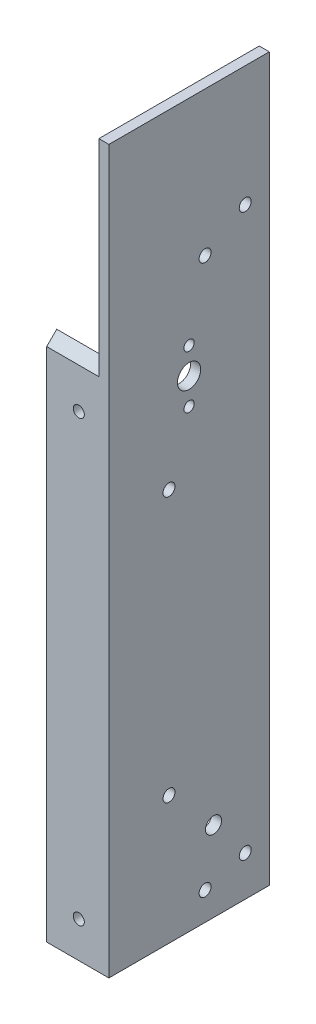
from build123d import *

# Parameters (mm, degrees)
BOSS_EXTRUDE1_DEPTH     = 203.2
CUT_EXTRUDE3_DEPTH      = 17.51
CUT_EXTRUDE3_DEPTH_BACK = 4.175
SKETCH7_R               = 3.683
SKETCH7_R_2             = 1.63195
CUT_EXTRUDE4_DEPTH      = 20.685
SKETCH8_R               = 1.89865
CUT_EXTRUDE5_DEPTH      = 4.175
SKETCH9_R               = 1.89865
CUT_EXTRUDE6_DEPTH      = 4.175
SKETCH10_R              = 1.7526
CUT_EXTRUDE7_DEPTH      = 4.175
BOSS_EXTRUDE2_DEPTH     = 3.175
SKETCH12_R              = 2.54
CUT_EXTRUDE8_DEPTH      = 4.175
SKETCH13_R              = 1.89865
CUT_EXTRUDE9_DEPTH      = 4.175


with BuildPart() as part:
    # Sketch1 → Boss-Extrude1 (new body)
    with BuildSketch(Plane(origin=(0, 0, 0), x_dir=(1, 0, 0), z_dir=(0, 1, 0))):
        Polygon((0, 0), (-19.685, 0), (-19.685, 3.175), (-3.175, 3.175), (-3.175, 50.8), (0, 50.8), align=None)
    extrude(amount=BOSS_EXTRUDE1_DEPTH)

    # Sketch5 → Cut-Extrude3 (cut, two sides)
    with BuildSketch(Plane.ZY.offset(3.175)) as cut_extrude3_sk:
        Polygon((0, 163.322), (-50.8, 214.122), (-60.823247691, 214.122), (-60.823247691, 256.047203652), (33.196571846, 256.047203652), (33.196571846, 163.322), align=None)
    extrude(amount=CUT_EXTRUDE3_DEPTH, mode=Mode.SUBTRACT)
    extrude(cut_extrude3_sk.sketch, amount=-CUT_EXTRUDE3_DEPTH_BACK, mode=Mode.SUBTRACT)

    # Sketch7 → Cut-Extrude4 (cut, through all)
    with BuildSketch(Plane(origin=(0, 0, 0), x_dir=(0, 0, -1), z_dir=(1, 0, 0))):
        with Locations((25.4, 152.4)):
            Circle(SKETCH7_R)
        with Locations((25.4, 160.782)):
            Circle(SKETCH7_R_2)
        with Locations((25.4, 144.018)):
            Circle(SKETCH7_R_2)
    extrude(amount=-CUT_EXTRUDE4_DEPTH, mode=Mode.SUBTRACT)

    # Sketch8 → Cut-Extrude5 (cut, through all)
    with BuildSketch(Plane.ZY.offset(3.175)):
        with Locations((-30.48, 182.88)):
            Circle(SKETCH8_R)
        with Locations((-30.48, 8.89)):
            Circle(SKETCH8_R)
    extrude(amount=-CUT_EXTRUDE5_DEPTH, mode=Mode.SUBTRACT)

    # Sketch9 → Cut-Extrude6 (cut, through all)
    with BuildSketch(Plane.ZY.offset(3.175)):
        with Locations((-19.05, 40.577339992)):
            Circle(SKETCH9_R)
        with Locations((-19.05, 124.397339992)):
            Circle(SKETCH9_R)
    extrude(amount=-CUT_EXTRUDE6_DEPTH, mode=Mode.SUBTRACT)

    # Sketch10 → Cut-Extrude7 (cut, through all)
    with BuildSketch(Plane(origin=(0, 0, -3.175), x_dir=(-1, 0, 0), z_dir=(0, 0, -1))):
        with Locations((9.525, 11.43)):
            Circle(SKETCH10_R)
        with Locations((9.525, 150.603948776)):
            Circle(SKETCH10_R)
    extrude(amount=-CUT_EXTRUDE7_DEPTH, mode=Mode.SUBTRACT)

    # Sketch11 → Boss-Extrude2 (add)
    with BuildSketch(Plane(origin=(0, 0, 0), x_dir=(0, 0, -1), z_dir=(1, 0, 0))):
        Polygon((0, 228.6), (0, 163.322), (39.878, 203.2), (50.8, 203.2), (50.8, 228.6), align=None)
    extrude(amount=-BOSS_EXTRUDE2_DEPTH)

    # Sketch12 → Cut-Extrude8 (cut, through all)
    with BuildSketch(Plane.ZY.offset(3.175)):
        with Locations((-33.136196499, 25.4)):
            Circle(SKETCH12_R)
    extrude(amount=-CUT_EXTRUDE8_DEPTH, mode=Mode.SUBTRACT)

    # Sketch13 → Cut-Extrude9 (cut, through all)
    with BuildSketch(Plane.ZY.offset(3.175)):
        with Locations((-43.18, 12.7)):
            Circle(SKETCH13_R)
        with Locations((-43.18, 190.498941664)):
            Circle(SKETCH13_R)
    extrude(amount=-CUT_EXTRUDE9_DEPTH, mode=Mode.SUBTRACT)


solid = part.part
